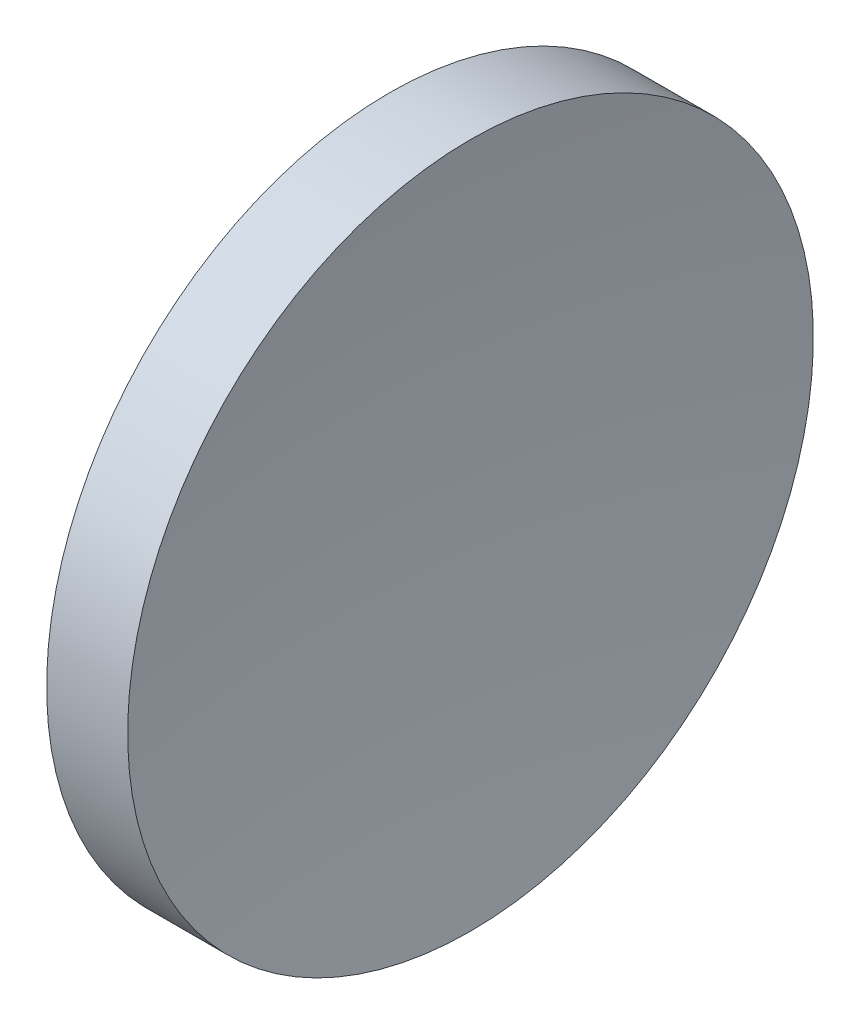
from build123d import *


with BuildPart() as part:
    # 草图1 → 旋转1 (revolve)
    with BuildSketch(Plane.XY, mode=Mode.PRIVATE) as revolve_1_sk:
        with BuildLine():
            Line((57.358190158, 32.578725913), (57.358190158, 45.078725913))
            Line((57.358190158, 45.078725913), (60.31197721, 45.078725913))
            ThreePointArc((60.31197721, 45.078725913), (59.597655794, 38.846842365), (59.358190158, 32.578725913))
            Line((59.358190158, 32.578725913), (57.358190158, 32.578725913))
        make_face()
    revolve(revolve_1_sk.sketch.rotate(Axis((55.007394624, 32.578725913, 0), (1, 0, 0)), 180), axis=Axis((55.007394624, 32.578725913, 0), (1, 0, 0)))  # turned: the seam where the file's is


solid = part.part
